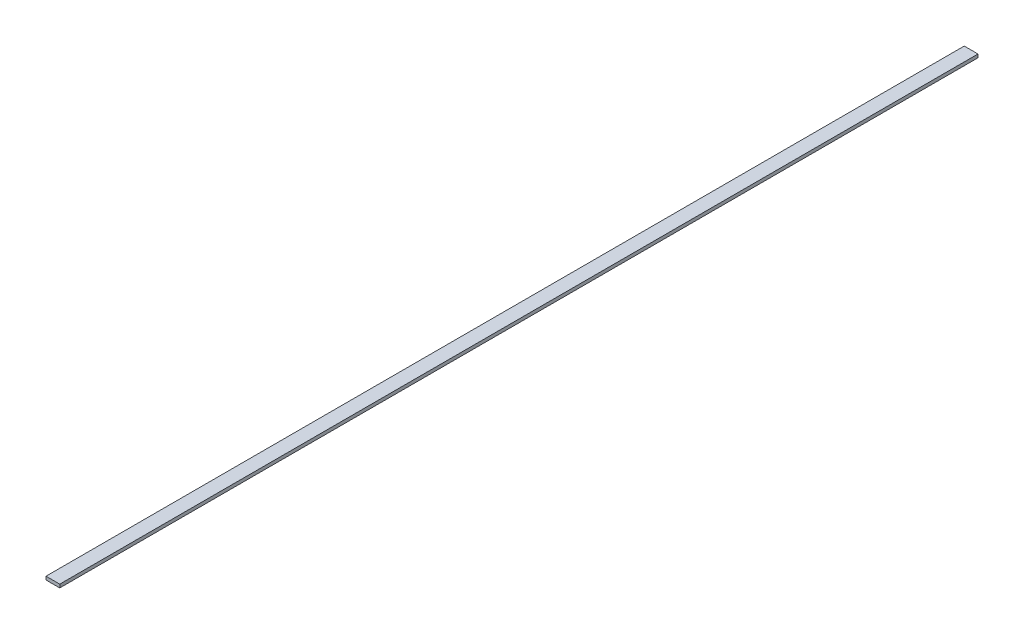
from build123d import *

# Parameters (mm, degrees)
CROQUIS1_W              = 6.2
CROQUIS1_H              = 414
SALIENTE_EXTRUIR1_DEPTH = 1.5


with BuildPart() as part:
    # Croquis1 → Saliente-Extruir1 (new body)
    with BuildSketch(Plane(origin=(0, 0, 0), x_dir=(1, 0, 0), z_dir=(0, 1, 0))):
        with Locations((3.1, 207)):
            Rectangle(CROQUIS1_W, CROQUIS1_H)
    extrude(amount=SALIENTE_EXTRUIR1_DEPTH)


solid = part.part
